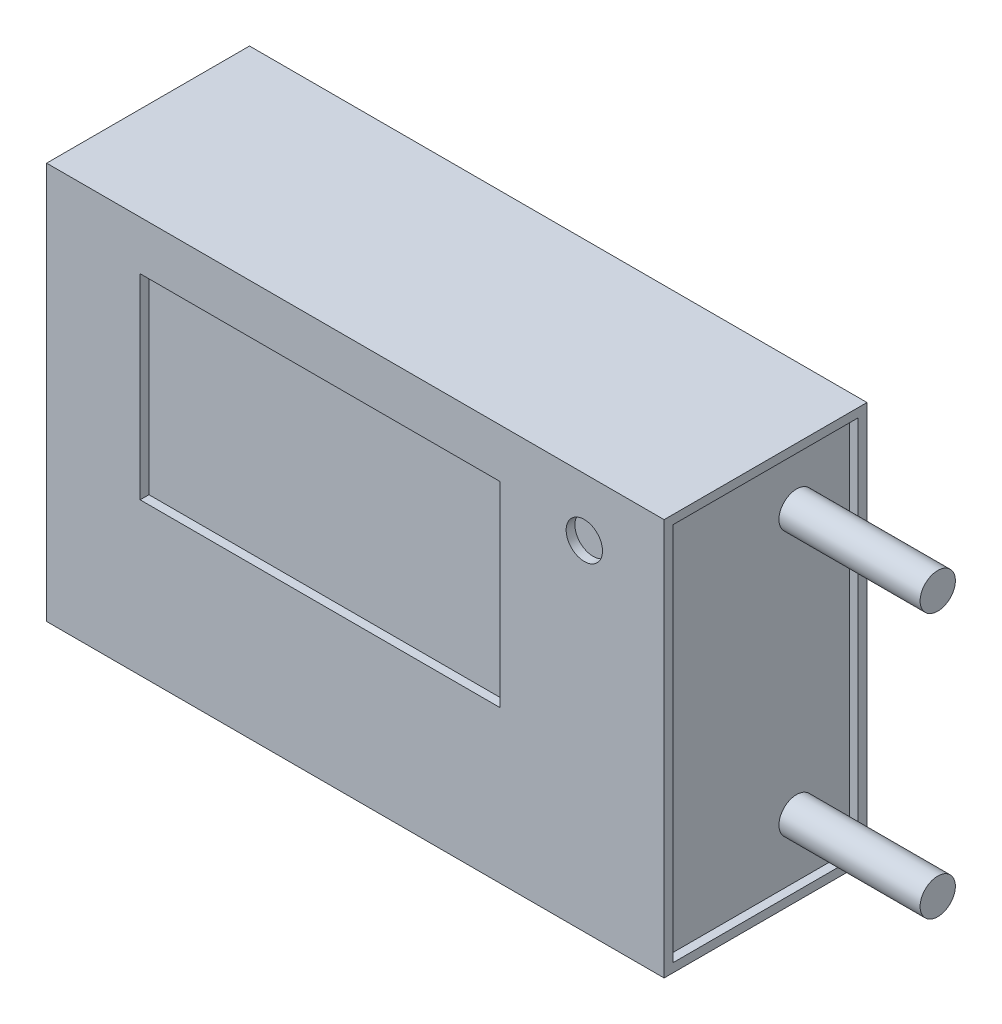
from build123d import *

# Parameters (mm, degrees)
SKETCH1_W           = 42
SKETCH1_H           = 22.5
BOSS_EXTRUDE1_DEPTH = 5.75
SKETCH2_W           = 10.5
SKETCH2_H           = 21.5
CUT_EXTRUDE1_DEPTH  = 4
SKETCH3_R           = 1
BOSS_EXTRUDE2_DEPTH = 8
SKETCH4_R           = 0.5
BOSS_EXTRUDE3_DEPTH = 8
SKETCH5_R           = 1.030633651
SKETCH5_W           = 20.392034512
SKETCH5_H           = 11.098868447
CUT_EXTRUDE2_DEPTH  = 0.5
SKETCH9_W           = 11.5
SKETCH9_H           = 22.5
SKETCH9_W_2         = 10.5
SKETCH9_H_2         = 21.5
CUT_EXTRUDE5_DEPTH  = 3.5
SKETCH10_W          = 11.5
SKETCH10_H          = 22.5
SKETCH10_W_2        = 10.5
SKETCH10_H_2        = 21.5
CUT_EXTRUDE6_DEPTH  = 3.5


with BuildPart() as part:
    # Sketch1 → Boss-Extrude1 (new body, symmetric)
    with BuildSketch(Plane.XY):
        Rectangle(SKETCH1_W, SKETCH1_H)
    extrude(amount=BOSS_EXTRUDE1_DEPTH, both=True)

    # Sketch2 → Cut-Extrude1 (cut)
    with BuildSketch(Plane(origin=(21, 0, 0), x_dir=(0, 0, -1), z_dir=(1, 0, 0))):
        Rectangle(SKETCH2_W, SKETCH2_H)
    cut_extrude1 = extrude(amount=-CUT_EXTRUDE1_DEPTH, mode=Mode.SUBTRACT)

    # Mirror1: Cut-Extrude1 across plane
    add(cut_extrude1.mirror(Plane(origin=(0, 0, 0), x_dir=(0, 0, 1), z_dir=(1, 0, 0))), mode=Mode.SUBTRACT)

    # Sketch3 → Boss-Extrude2 (add)
    with BuildSketch(Plane(origin=(17, 0, 0), x_dir=(0, 0, -1), z_dir=(1, 0, 0))):
        with Locations((2.259944465, 7.5)):
            Circle(SKETCH3_R)
        with Locations((2.259944465, -7.5)):
            Circle(SKETCH3_R)
    extrude(amount=BOSS_EXTRUDE2_DEPTH)

    # Sketch4 → Boss-Extrude3 (add)
    with BuildSketch(Plane.ZY.offset(17)):
        with Locations((-3.364806204, 2.988148793)):
            Circle(SKETCH4_R)
        with Locations((-3.364806204, -2.988148793)):
            Circle(SKETCH4_R)
    extrude(amount=BOSS_EXTRUDE3_DEPTH)

    # Sketch5 → Cut-Extrude2 (cut)
    with BuildSketch(Plane.XY.offset(5.75)):
        with Locations((12.976825893, 7.964601522)):
            Circle(SKETCH5_R)
        with Locations((-2.003815564, 2.9231166)):
            Rectangle(SKETCH5_W, SKETCH5_H)
    extrude(amount=-CUT_EXTRUDE2_DEPTH, mode=Mode.SUBTRACT)

    # Sketch9 → Cut-Extrude5 (cut)
    with BuildSketch(Plane(origin=(21, 0, 0), x_dir=(0, 0, -1), z_dir=(1, 0, 0))):
        Rectangle(SKETCH9_W, SKETCH9_H)
        Rectangle(SKETCH9_W_2, SKETCH9_H_2, mode=Mode.SUBTRACT)
    extrude(amount=-CUT_EXTRUDE5_DEPTH, mode=Mode.SUBTRACT)

    # Sketch10 → Cut-Extrude6 (cut)
    with BuildSketch(Plane.ZY.offset(21)):
        Rectangle(SKETCH10_W, SKETCH10_H)
        Rectangle(SKETCH10_W_2, SKETCH10_H_2, mode=Mode.SUBTRACT)
    extrude(amount=-CUT_EXTRUDE6_DEPTH, mode=Mode.SUBTRACT)


solid = part.part
